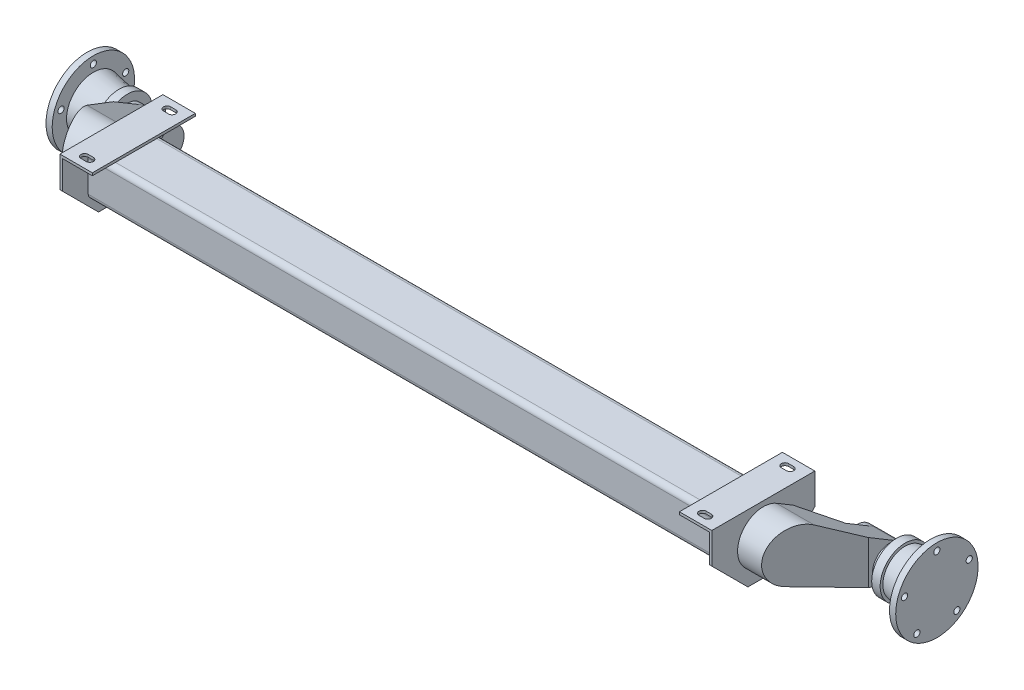
from build123d import *

# Parameters (mm, degrees)
CUT_EXTRUDE1_REACH      = 157
SKETCH2_R               = 6
BOSS_EXTRUDE1_DEPTH     = 633
BOSS_EXTRUDE2_DEPTH     = 5
SKETCH6_W               = 63
SKETCH6_H               = 200
BOSS_EXTRUDE3_DEPTH     = 5
BOSS_EXTRUDE4_DEPTH     = 100
CUT_EXTRUDE2_DEPTH      = 128
CUT_EXTRUDE2_DEPTH_BACK = 81


with BuildPart() as part:
    # Sketch1 → Revolve1 (revolve)
    with BuildSketch(Plane(origin=(0, 0, 0), x_dir=(1, 0, 0), z_dir=(0, 1, 0))):
        Polygon((825, 0), (825, 80), (813, 80), (813, 52.102452079), (763.258124913, 43.215384463), (763.258124913, 48.450903374), (746.851230852, 48.450903374), (746.851230852, 33.013608417), (670, 33.013608417), (670, 0), align=None)
    revolve(axis=Axis((657.896171738, 0, 0), (1, 0, 0)))

    # Sketch2 → Cut-Extrude1 (cut, up to next)
    with BuildSketch(Plane(origin=(825, 0, 0), x_dir=(0, 0, -1), z_dir=(1, 0, 0)), mode=Mode.PRIVATE) as cut_extrude1_sk1:
        with Locations((0, 66)):
            Circle(SKETCH2_R)
    cut_extrude1_tool1 = extrude(cut_extrude1_sk1.sketch, amount=-CUT_EXTRUDE1_REACH, mode=Mode.PRIVATE) & part.part
    add(cut_extrude1_tool1.solids().sort_by_distance((825, 66, 0))[0], mode=Mode.SUBTRACT)
    # Sketch2 → Cut-Extrude1 (cut, up to next)
    with BuildSketch(Plane(origin=(825, 0, 0), x_dir=(0, 0, -1), z_dir=(1, 0, 0)), mode=Mode.PRIVATE) as cut_extrude1_sk2:
        with Locations((62.769730075, 20.395121629)):
            Circle(SKETCH2_R)
    cut_extrude1_tool2 = extrude(cut_extrude1_sk2.sketch, amount=-CUT_EXTRUDE1_REACH, mode=Mode.PRIVATE) & part.part
    add(cut_extrude1_tool2.solids().sort_by_distance((825, 20.395122, -62.76973))[0], mode=Mode.SUBTRACT)
    # Sketch2 → Cut-Extrude1 (cut, up to next)
    with BuildSketch(Plane(origin=(825, 0, 0), x_dir=(0, 0, -1), z_dir=(1, 0, 0)), mode=Mode.PRIVATE) as cut_extrude1_sk3:
        with Locations((38.793826651, -53.395121629)):
            Circle(SKETCH2_R)
    cut_extrude1_tool3 = extrude(cut_extrude1_sk3.sketch, amount=-CUT_EXTRUDE1_REACH, mode=Mode.PRIVATE) & part.part
    add(cut_extrude1_tool3.solids().sort_by_distance((825, -53.395122, -38.793827))[0], mode=Mode.SUBTRACT)
    # Sketch2 → Cut-Extrude1 (cut, up to next)
    with BuildSketch(Plane(origin=(825, 0, 0), x_dir=(0, 0, -1), z_dir=(1, 0, 0)), mode=Mode.PRIVATE) as cut_extrude1_sk4:
        with Locations((-38.793826651, -53.395121629)):
            Circle(SKETCH2_R)
    cut_extrude1_tool4 = extrude(cut_extrude1_sk4.sketch, amount=-CUT_EXTRUDE1_REACH, mode=Mode.PRIVATE) & part.part
    add(cut_extrude1_tool4.solids().sort_by_distance((825, -53.395122, 38.793827))[0], mode=Mode.SUBTRACT)
    # Sketch2 → Cut-Extrude1 (cut, up to next)
    with BuildSketch(Plane(origin=(825, 0, 0), x_dir=(0, 0, -1), z_dir=(1, 0, 0)), mode=Mode.PRIVATE) as cut_extrude1_sk5:
        with Locations((-62.769730075, 20.395121629)):
            Circle(SKETCH2_R)
    cut_extrude1_tool5 = extrude(cut_extrude1_sk5.sketch, amount=-CUT_EXTRUDE1_REACH, mode=Mode.PRIVATE) & part.part
    add(cut_extrude1_tool5.solids().sort_by_distance((825, 20.395122, 62.76973))[0], mode=Mode.SUBTRACT)


with BuildPart() as body_2:
    # Sketch4 → Boss-Extrude1 (new body)
    with BuildSketch(Plane(origin=(0, 0, 0), x_dir=(0, 0, -1), z_dir=(1, 0, 0))):
        with BuildLine():
            Line((-185, 107), (-105, 107))
            ThreePointArc((-105, 107), (-97.928932188, 104.071067812), (-95, 97))
            Line((-95, 97), (-95, 37))
            ThreePointArc((-95, 37), (-97.928932188, 29.928932188), (-105, 27))
            Line((-105, 27), (-185, 27))
            ThreePointArc((-185, 27), (-192.071067812, 29.928932188), (-195, 37))
            Line((-195, 37), (-195, 97))
            ThreePointArc((-195, 97), (-192.071067812, 104.071067812), (-185, 107))
        make_face()
    extrude(amount=BOSS_EXTRUDE1_DEPTH)

    # Sketch5 → Boss-Extrude2 (add)
    with BuildSketch(Plane(origin=(633, 0, 0), x_dir=(0, 0, -1), z_dir=(1, 0, 0))):
        Polygon((-245, 127), (-45, 127), (-45, 67), (-115, -3), (-175, -3), (-245, 67), align=None)
    extrude(amount=-BOSS_EXTRUDE2_DEPTH)

    # Sketch6 → Boss-Extrude3 (add)
    with BuildSketch(Plane(origin=(0, 127, 0), x_dir=(1, 0, 0), z_dir=(0, 1, 0))):
        with Locations((601.5, -145)):
            Rectangle(SKETCH6_W, SKETCH6_H)
        with BuildLine():
            Line((595, -58), (605, -58))
            ThreePointArc((605, -58), (612, -65), (605, -72))
            Line((605, -72), (595, -72))
            ThreePointArc((595, -72), (588, -65), (595, -58))
        make_face(mode=Mode.SUBTRACT)
        with BuildLine():
            Line((595, -232), (605, -232))
            ThreePointArc((605, -232), (612, -225), (605, -218))
            Line((605, -218), (595, -218))
            ThreePointArc((595, -218), (588, -225), (595, -232))
        make_face(mode=Mode.SUBTRACT)
    extrude(amount=-BOSS_EXTRUDE3_DEPTH)


with BuildPart() as body_3:
    # Sketch7 → Boss-Extrude4 (new body)
    with BuildSketch(Plane(origin=(633, 0, 0), x_dir=(0, 0, -1), z_dir=(1, 0, 0))):
        with BuildLine():
            Line((-119.363743831, 109.927641091), (17.011140909, 28.484976382))
            ThreePointArc((17.011140909, 28.484976382), (30.118099961, -13.916639292), (-10.667353807, -31.416243525))
            Line((-10.667353807, -31.416243525), (-161.07599492, 19.654858884))
            ThreePointArc((-161.07599492, 19.654858884), (-190.388803142, 87.972757314), (-119.363743831, 109.927641091))
        make_face()
    extrude(amount=BOSS_EXTRUDE4_DEPTH)

    # Sketch8 → Cut-Extrude2 (cut, two sides)
    with BuildSketch(Plane(origin=(0, 0, 0), x_dir=(1, 0, 0), z_dir=(0, 1, 0))) as cut_extrude2_sk:
        Polygon((684.125986069, 52.172184326), (684.125986069, -36.03915177), (633, -87.375021277), (621.083181111, -87.375021277), (621.083181111, 52.172184326), align=None)
        Polygon((762.556990908, -18.927195268), (740.647296939, -18.927195268), (670.961767899, -219.892834515), (762.556990908, -219.892834515), align=None)
    extrude(amount=CUT_EXTRUDE2_DEPTH, mode=Mode.SUBTRACT)
    extrude(cut_extrude2_sk.sketch, amount=-CUT_EXTRUDE2_DEPTH_BACK, mode=Mode.SUBTRACT)


with BuildPart() as body_2_1:
    add(body_2.part)

    # Combine1: union body 3, part
    add(body_3.part)
    add(part.part)

    # Mirror4: body 2 across plane


with BuildPart() as body_2_2:
    add(body_2_1.part)
    add(body_2_1.part.mirror(Plane(origin=(0, 0, 0), x_dir=(0, 0, 1), z_dir=(1, 0, 0))))


solid = body_2_2.part
